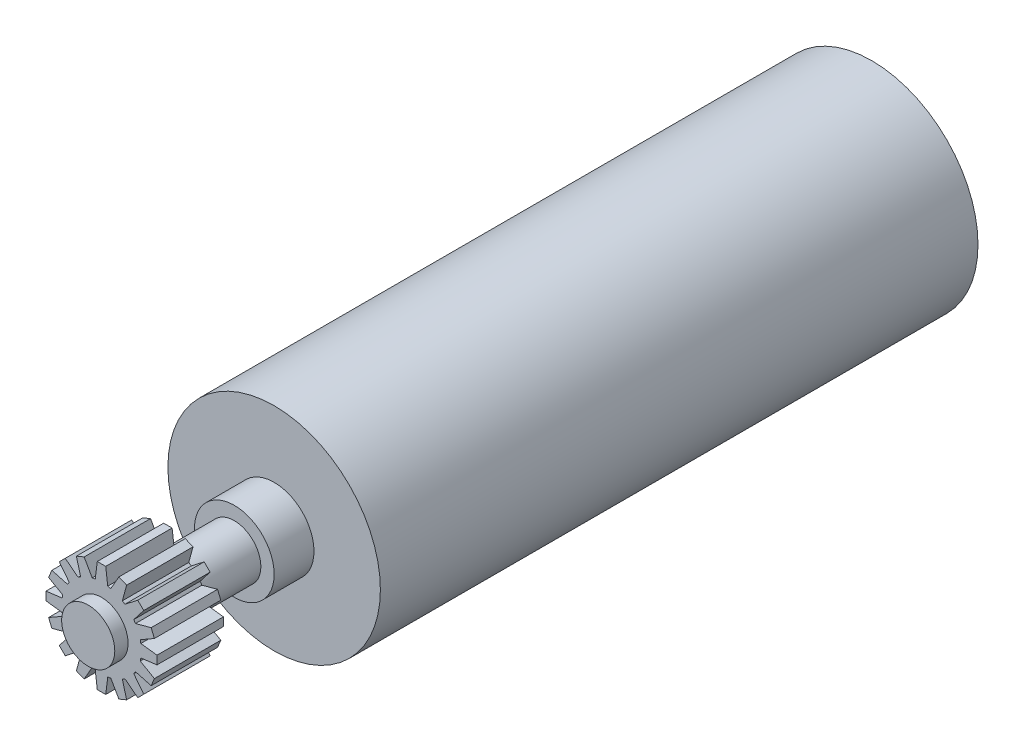
from build123d import *

# Parameters (mm, degrees)
ESBO_O1_R                = 8
RESSALTO_EXTRUS_O1_DEPTH = 45
ESBO_O2_R                = 3
RESSALTO_EXTRUS_O2_DEPTH = 3
ESBO_O3_R                = 2
RESSALTO_EXTRUS_O3_DEPTH = 5
ESBO_O4_R                = 3
RESSALTO_EXTRUS_O4_DEPTH = 5
ESBO_O5_R                = 2
RESSALTO_EXTRUS_O5_DEPTH = 1
RESSALTO_EXTRUS_O6_DEPTH = 5
PADR_OCIRCULAR1_COUNT    = 16


with BuildPart() as part:
    # Esboço1 → Ressalto-extrusão1 (new body)
    with BuildSketch(Plane.XY):
        Circle(ESBO_O1_R)
    extrude(amount=RESSALTO_EXTRUS_O1_DEPTH)

    # Esboço2 → Ressalto-extrusão2 (add)
    with BuildSketch(Plane.XY.offset(45)):
        Circle(ESBO_O2_R)
    extrude(amount=RESSALTO_EXTRUS_O2_DEPTH)

    # Esboço3 → Ressalto-extrusão3 (add)
    with BuildSketch(Plane.XY.offset(48)):
        Circle(ESBO_O3_R)
    extrude(amount=RESSALTO_EXTRUS_O3_DEPTH)

    # Esboço4 → Ressalto-extrusão4 (add)
    with BuildSketch(Plane.XY.offset(53)):
        Circle(ESBO_O4_R)
    extrude(amount=RESSALTO_EXTRUS_O4_DEPTH)

    # Esboço5 → Ressalto-extrusão5 (add)
    with BuildSketch(Plane.XY.offset(58)):
        Circle(ESBO_O5_R)
    extrude(amount=RESSALTO_EXTRUS_O5_DEPTH)

    # Esboço6 → Ressalto-extrusão6 (add)
    with BuildSketch(Plane.XY.offset(58)):
        Polygon((-0.5, 2.735669954), (-0.317294901, 4.179040235), (0.317294901, 4.179040235), (0.5, 2.735669954), align=None)
    ressalto_extrus_o6 = extrude(amount=-RESSALTO_EXTRUS_O6_DEPTH)

    # PadrãoCircular1: Ressalto-extrusão6 ×16 about axis
    padr_ocircular1_axis = Axis((0, 0, 0), (0, 0, 1))
    for i in range(1, PADR_OCIRCULAR1_COUNT):
        add(ressalto_extrus_o6.rotate(padr_ocircular1_axis, i * 360 / PADR_OCIRCULAR1_COUNT))


solid = part.part
